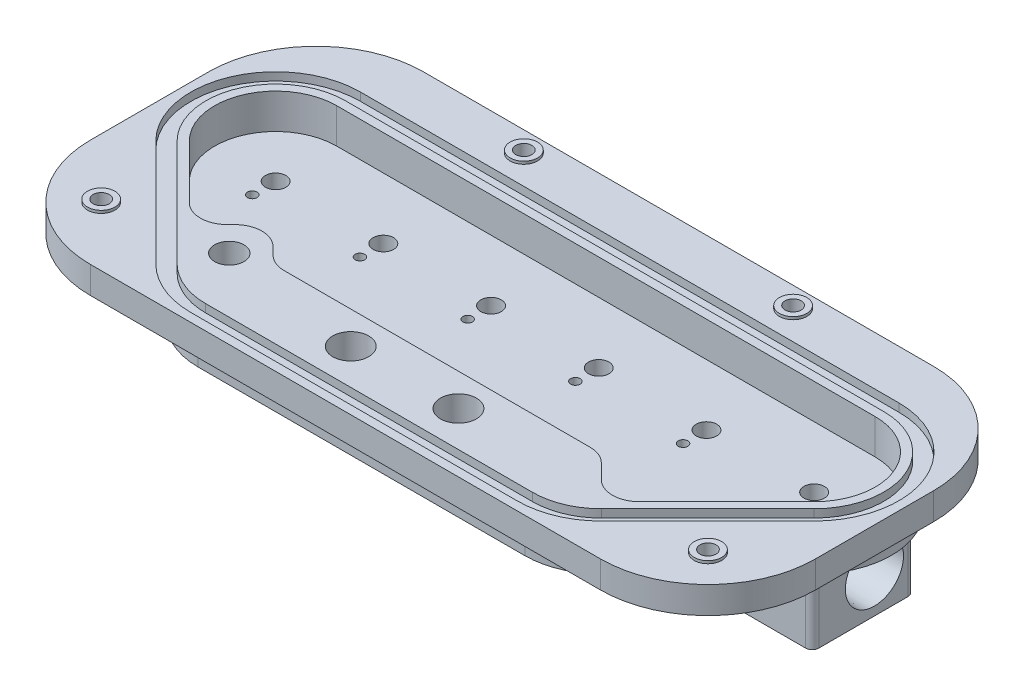
from build123d import *

# Parameters (mm, degrees)
BOSS_EXTRUDE1_DEPTH              = 12.065
SHELL1_T                         = -3.81
SKETCH3_W                        = 24.13
SKETCH3_H                        = 17.78
BOSS_EXTRUDE2_DEPTH              = 74.295
FILLET1_R                        = 1.5875
F_10_32_TAPPED_HOLE1_D           = 4.0386
F_10_32_TAPPED_HOLE1_DEPTH       = 12.02944
F_10_32_TAPPED_HOLE1_CBORE_D     = 4.826
F_10_32_TAPPED_HOLE1_CBORE_DEPTH = 9.652
F_10_32_TAPPED_HOLE1_TIP         = 1.213317848
F_7_16_0_4375_DIAMETER_HOLE5_D   = 11.1125
F_43_0_089_DIAMETER_HOLE2_D      = 2.2606
F_43_0_089_DIAMETER_HOLE2_DEPTH  = 36.068
F_43_0_089_DIAMETER_HOLE2_TIP    = 0.679152758
F_10_32_TAPPED_HOLE2_D           = 4.0386
F_10_32_TAPPED_HOLE2_DEPTH       = 5.08
F_10_32_TAPPED_HOLE2_CBORE_D     = 4.826
F_10_32_TAPPED_HOLE2_CBORE_DEPTH = 3.81
F_10_32_TAPPED_HOLE2_TIP         = 1.213317848
SKETCH12_W                       = 171.0436
SKETCH12_H                       = 78.613
BOSS_EXTRUDE3_DEPTH              = 6.35
BOSS_EXTRUDE6_DEPTH              = 8.255
FILLET5_R                        = 6.35
BOSS_EXTRUDE7_DEPTH              = 6.35
FILLET6_R                        = 6.35
F_4_40_TAPPED_HOLE1_D            = 2.2606
F_4_40_TAPPED_HOLE1_DEPTH        = 5.715
F_4_40_TAPPED_HOLE1_CBORE_D      = 2.8448
F_4_40_TAPPED_HOLE1_CBORE_DEPTH  = 3.81
F_4_40_TAPPED_HOLE1_TIP          = 0.679152758
F_5_16_24_TAPPED_HOLE1_D         = 6.9088
CUT_EXTRUDE7_DEPTH               = 1.905
FILLET7_R                        = 25.4
M10X1_5_TAPPED_HOLE1_D           = 8.5
F_6_CLEARANCE_HOLE1_D            = 3.7973
SKETCH59_R                       = 3.2385
SKETCH59_R_2                     = 1.89865
BOSS_EXTRUDE8_DEPTH              = 0.635
SKETCH64_R                       = 5.08
CUT_EXTRUDE9_DEPTH               = 5


with BuildPart() as part:
    # Sketch1 → Boss-Extrude1 (new body)
    with BuildSketch(Plane(origin=(0, 0, 0), x_dir=(1, 0, 0), z_dir=(0, 1, 0))):
        with BuildLine():
            Line((-63.5, 18.034), (63.5, 18.034))
            ThreePointArc((63.5, 18.034), (80.32550927, 6.791554134), (76.377687278, -13.055487278))
            Line((76.377687278, -13.055487278), (51.281210863, -38.151963692))
            ThreePointArc((51.281210863, -38.151963692), (45.430560191, -42.061243489), (38.529247171, -43.434))
            Line((38.529247171, -43.434), (-38.529247171, -43.434))
            ThreePointArc((-38.529247171, -43.434), (-45.430560191, -42.061243489), (-51.281210863, -38.151963692))
            Line((-51.281210863, -38.151963692), (-76.377687278, -13.055487278))
            ThreePointArc((-76.377687278, -13.055487278), (-80.32550927, 6.791554134), (-63.5, 18.034))
        make_face()
    extrude(amount=BOSS_EXTRUDE1_DEPTH)

    # Shell1
    shell1_openings = [part.faces().sort_by_distance(p)[0] for p in [
        (0, 12.065, 10.309491843),
    ]]
    offset(amount=SHELL1_T, openings=shell1_openings, kind=Kind.INTERSECTION)

    # Sketch3 → Boss-Extrude2 (add, symmetric)
    with BuildSketch(Plane(origin=(0, 0, 0), x_dir=(0, 0, -1), z_dir=(1, 0, 0))):
        with Locations((0.635, -8.89)):
            Rectangle(SKETCH3_W, SKETCH3_H)
    extrude(amount=BOSS_EXTRUDE2_DEPTH, both=True)

    # Fillet1
    fillet1_edges = [part.edges().sort_by_distance(p)[0] for p in [
        (-74.295, -8.89, 11.43),
        (-74.295, -8.89, -12.7),
        (74.295, -8.89, 11.43),
        (74.295, -8.89, -12.7),
    ]]
    fillet(fillet1_edges, radius=FILLET1_R)

    # #10-32 Tapped Hole1
    with Locations(Plane(origin=(0, 3.81, 0), x_dir=(1, 0, 0), z_dir=(0, 1, 0))):
        with Locations((-63.5, -0.1778), (-38.1, -0.1778), (-12.7, -0.1778), (12.7, -0.1778), (38.1, -0.1778), (63.5, -0.1778)):
            CounterBoreHole(F_10_32_TAPPED_HOLE1_D / 2, F_10_32_TAPPED_HOLE1_CBORE_D / 2, F_10_32_TAPPED_HOLE1_CBORE_DEPTH, depth=F_10_32_TAPPED_HOLE1_DEPTH)
            with Locations((0, 0, -(F_10_32_TAPPED_HOLE1_DEPTH + F_10_32_TAPPED_HOLE1_TIP / 2))):  # 118° drill point
                Cone(0, F_10_32_TAPPED_HOLE1_D / 2, F_10_32_TAPPED_HOLE1_TIP, mode=Mode.SUBTRACT)

    # 7/16 (0.4375) Diameter Hole5 (through all)
    with Locations(Plane.ZY.offset(74.295)):
        with Locations((-3.2385, -8.89)):
            Hole(F_7_16_0_4375_DIAMETER_HOLE5_D / 2)

    # Sketch61 → 1/4 NPT Tapped Hole2 (revolve, cut)
    with BuildSketch(Plane(origin=(74.295, -8.89, -3.2385), x_dir=(0, 0, -1), z_dir=(0, 1, 0))):
        Polygon((0, 0), (0, 156.0068), (5.5626, 156.0068), (5.5626, 9.906), (6.557984794, 9.906), (6.8545837, 0), align=None)
    revolve(axis=Axis((80.645, -8.89, -3.2385), (-1, 0, 0)), mode=Mode.SUBTRACT)

    # Sketch63 → 1/4 NPT Tapped Hole3 (revolve, cut)
    with BuildSketch(Plane(origin=(-74.295, -8.89, -3.2385), x_dir=(0, 0, 1), z_dir=(0, 1, 0))):
        Polygon((0, 0), (0, 156.0068), (5.5626, 156.0068), (5.5626, 9.906), (6.557984794, 9.906), (6.8545837, 0), align=None)
    revolve(axis=Axis((-80.645, -8.89, -3.2385), (1, 0, 0)), mode=Mode.SUBTRACT)

    # #43 (0.089) Diameter Hole2
    with Locations(Plane(origin=(0, 3.81, 0), x_dir=(1, 0, 0), z_dir=(0, 1, 0))):
        with Locations((-63.5, -5.6896), (-38.1, -5.6896), (-12.7, -5.6896), (12.7, -5.6896), (38.1, -5.6896), (63.5, -5.6896)):
            Hole(F_43_0_089_DIAMETER_HOLE2_D / 2, depth=F_43_0_089_DIAMETER_HOLE2_DEPTH)
            with Locations((0, 0, -(F_43_0_089_DIAMETER_HOLE2_DEPTH + F_43_0_089_DIAMETER_HOLE2_TIP / 2))):  # 118° drill point
                Cone(0, F_43_0_089_DIAMETER_HOLE2_D / 2, F_43_0_089_DIAMETER_HOLE2_TIP, mode=Mode.SUBTRACT)

    # #10-32 Tapped Hole2
    with Locations(Plane(origin=(0, -17.78, 0), x_dir=(-1, 0, 0), z_dir=(0, -1, 0))):
        with Locations((63.5, -5.6896), (38.1, -5.6896), (12.7, -5.6896), (-12.7, -5.6896), (-38.1, -5.6896), (-63.5, -5.6896)):
            CounterBoreHole(F_10_32_TAPPED_HOLE2_D / 2, F_10_32_TAPPED_HOLE2_CBORE_D / 2, F_10_32_TAPPED_HOLE2_CBORE_DEPTH, depth=F_10_32_TAPPED_HOLE2_DEPTH)
            with Locations((0, 0, -(F_10_32_TAPPED_HOLE2_DEPTH + F_10_32_TAPPED_HOLE2_TIP / 2))):  # 118° drill point
                Cone(0, F_10_32_TAPPED_HOLE2_D / 2, F_10_32_TAPPED_HOLE2_TIP, mode=Mode.SUBTRACT)

    # Sketch12 → Boss-Extrude3 (add)
    with BuildSketch(Plane(origin=(0, 12.065, 0), x_dir=(1, 0, 0), z_dir=(0, 1, 0))):
        with Locations((0, -7.9375)):
            Rectangle(SKETCH12_W, SKETCH12_H)
        with BuildLine():
            Line((63.5, 14.224), (-63.5, 14.224))
            ThreePointArc((-63.5, 14.224), (-76.805528251, 5.333530256), (-73.683610441, -10.361410441))
            Line((-73.683610441, -10.361410441), (-48.587134027, -35.457886856))
            ThreePointArc((-48.587134027, -35.457886856), (-43.972536313, -38.54126247), (-38.529247171, -39.624))
            Line((-38.529247171, -39.624), (38.529247171, -39.624))
            ThreePointArc((38.529247171, -39.624), (43.972536313, -38.54126247), (48.587134027, -35.457886856))
            Line((48.587134027, -35.457886856), (73.683610441, -10.361410441))
            ThreePointArc((73.683610441, -10.361410441), (76.805528251, 5.333530256), (63.5, 14.224))
        make_face(mode=Mode.SUBTRACT)
    extrude(amount=-BOSS_EXTRUDE3_DEPTH)

    # Sketch21 → Boss-Extrude6 (add)
    with BuildSketch(Plane(origin=(0, 3.81, 0), x_dir=(1, 0, 0), z_dir=(0, 1, 0))):
        with BuildLine():
            Line((-56.594969658, -27.450051224), (-48.587134027, -35.457886856))
            ThreePointArc((-48.587134027, -35.457886856), (-43.972536313, -38.54126247), (-38.529247171, -39.624))
            Line((-38.529247171, -39.624), (38.529247171, -39.624))
            ThreePointArc((38.529247171, -39.624), (43.972536313, -38.54126247), (48.587134027, -35.457886856))
            Line((48.587134027, -35.457886856), (38.783247171, -25.654))
            Line((38.783247171, -25.654), (-38.634457416, -25.654))
            Line((-38.634457416, -25.654), (-46.716687925, -17.571769491))
            Line((-46.716687925, -17.571769491), (-56.594969658, -27.450051224))
        make_face()
    extrude(amount=BOSS_EXTRUDE6_DEPTH)

    # Fillet5
    fillet5_edges = [part.edges().sort_by_distance(p)[0] for p in [
        (48.587134027, 7.9375, 35.457886856),
        (38.783247171, 7.9375, 25.654),
        (-38.634457416, 7.9375, 25.654),
        (-46.716687925, 7.9375, 17.571769491),
        (-56.594969658, 7.9375, 27.450051224),
    ]]
    fillet(fillet5_edges, radius=FILLET5_R)

    # Sketch28 → Boss-Extrude7 (add)
    with BuildSketch(Plane.XZ):
        with BuildLine():
            Line((-25.248364969, 23.131039796), (-20.401635591, 11.43))
            Line((-20.401635591, 11.43), (-41.828364409, 11.43))
            Line((-41.828364409, 11.43), (-36.981635031, 23.131039796))
            ThreePointArc((-36.981635031, 23.131039796), (-31.115, 27.051), (-25.248364969, 23.131039796))
        make_face()
        with BuildLine():
            Line((25.248364969, 23.131039796), (20.401635591, 11.43))
            Line((20.401635591, 11.43), (41.828364409, 11.43))
            Line((41.828364409, 11.43), (36.981635031, 23.131039796))
            ThreePointArc((36.981635031, 23.131039796), (31.115, 27.051), (25.248364969, 23.131039796))
        make_face()
    extrude(amount=BOSS_EXTRUDE7_DEPTH)

    # Fillet6
    fillet6_edges = [part.edges().sort_by_distance(p)[0] for p in [
        (-41.828364409, -3.175, 11.43),
        (-20.401635591, -3.175, 11.43),
        (20.401635591, -3.175, 11.43),
        (41.828364409, -3.175, 11.43),
    ]]
    fillet(fillet6_edges, radius=FILLET6_R)

    # #4-40 Tapped Hole1
    with Locations(Plane(origin=(0, 3.81, 0), x_dir=(1, 0, 0), z_dir=(0, 1, 0))):
        with Locations((-31.115, -20.701), (31.115, -20.701)):
            CounterBoreHole(F_4_40_TAPPED_HOLE1_D / 2, F_4_40_TAPPED_HOLE1_CBORE_D / 2, F_4_40_TAPPED_HOLE1_CBORE_DEPTH, depth=F_4_40_TAPPED_HOLE1_DEPTH)
            with Locations((0, 0, -(F_4_40_TAPPED_HOLE1_DEPTH + F_4_40_TAPPED_HOLE1_TIP / 2))):  # 118° drill point
                Cone(0, F_4_40_TAPPED_HOLE1_D / 2, F_4_40_TAPPED_HOLE1_TIP, mode=Mode.SUBTRACT)

    # 5/16-24 Tapped Hole1 (through all)
    with Locations(Plane(origin=(0, 0, 0), x_dir=(-1, 0, 0), z_dir=(0, -1, 0))):
        with Locations((46.0375, -28.575)):
            Hole(F_5_16_24_TAPPED_HOLE1_D / 2)

    # Sketch54 → Cut-Extrude7 (cut)
    with BuildSketch(Plane(origin=(0, 12.065, -12.065), x_dir=(1, 0, 0), z_dir=(0, -1, 0))):
        with BuildLine():
            Line((38.529247171, 57.277), (-38.529247171, 57.277))
            ThreePointArc((-38.529247171, 57.277), (-46.110971333, 55.768901298), (-52.53844672, 51.474199549))
            Line((-52.53844672, 51.474199549), (-77.634923135, 26.377723135))
            ThreePointArc((-77.634923135, 26.377723135), (-81.968167079, 4.593034724), (-63.5, -7.747))
            Line((-63.5, -7.747), (63.5, -7.747))
            ThreePointArc((63.5, -7.747), (81.968167079, 4.593034724), (77.634923135, 26.377723135))
            Line((77.634923135, 26.377723135), (52.53844672, 51.474199549))
            ThreePointArc((52.53844672, 51.474199549), (46.110971333, 55.768901298), (38.529247171, 57.277))
        make_face()
        with BuildLine():
            Line((50.023975006, 48.959727835), (75.120451421, 23.863251421))
            ThreePointArc((75.120451421, 23.863251421), (78.682851461, 5.953857009), (63.5, -4.191))
            Line((63.5, -4.191), (-63.5, -4.191))
            ThreePointArc((-63.5, -4.191), (-78.682851461, 5.953857009), (-75.120451421, 23.863251421))
            Line((-75.120451421, 23.863251421), (-50.023975006, 48.959727835))
            ThreePointArc((-50.023975006, 48.959727835), (-44.750149048, 52.483585681), (-38.529247171, 53.721))
            Line((-38.529247171, 53.721), (38.529247171, 53.721))
            ThreePointArc((38.529247171, 53.721), (44.750149048, 52.483585681), (50.023975006, 48.959727835))
        make_face(mode=Mode.SUBTRACT)
    extrude(amount=CUT_EXTRUDE7_DEPTH, mode=Mode.SUBTRACT)

    # Fillet7
    fillet7_edges = [part.edges().sort_by_distance(p)[0] for p in [
        (-85.5218, 8.89, -31.369),
        (85.5218, 8.89, -31.369),
        (85.5218, 8.89, 47.244),
        (-85.5218, 8.89, 47.244),
    ]]
    fillet(fillet7_edges, radius=FILLET7_R)

    # M10x1.5 Tapped Hole1 (through all)
    with Locations(Plane(origin=(0, 12.065, 0), x_dir=(1, 0, 0), z_dir=(0, 1, 0))):
        with Locations((-12.7, -33.274), (12.7, -33.274)):
            Hole(M10X1_5_TAPPED_HOLE1_D / 2)

    # #6 Clearance Hole1 (through all)
    with Locations(Plane(origin=(0, 12.065, 0), x_dir=(1, 0, 0), z_dir=(0, 1, 0))):
        with Locations((-71.5518, -33.274), (-31.75, 26.6065), (71.5518, -33.274), (31.75, 26.6065)):
            Hole(F_6_CLEARANCE_HOLE1_D / 2)

    # Sketch59 → Boss-Extrude8 (add)
    with BuildSketch(Plane(origin=(0, 12.065, 0), x_dir=(1, 0, 0), z_dir=(0, 1, 0))):
        with Locations(Location((-31.75, 26.6065, 0), (0, 0, 270))):
            Circle(SKETCH59_R)
        with Locations(Location((-31.75, 26.6065, 0), (0, 0, 270))):
            Circle(SKETCH59_R_2, mode=Mode.SUBTRACT)
        with Locations(Location((-71.5518, -33.274, 0), (0, 0, 270))):
            Circle(SKETCH59_R)
        with Locations(Location((-71.5518, -33.274, 0), (0, 0, 270))):
            Circle(SKETCH59_R_2, mode=Mode.SUBTRACT)
        with Locations(Location((71.5518, -33.274, 0), (0, 0, 90))):
            Circle(SKETCH59_R)
        with Locations(Location((71.5518, -33.274, 0), (0, 0, 270))):
            Circle(SKETCH59_R_2, mode=Mode.SUBTRACT)
        with Locations(Location((31.75, 26.6065, 0), (0, 0, 90))):
            Circle(SKETCH59_R)
        with Locations(Location((31.75, 26.6065, 0), (0, 0, 270))):
            Circle(SKETCH59_R_2, mode=Mode.SUBTRACT)
    extrude(amount=BOSS_EXTRUDE8_DEPTH)

    # Sketch64 → Cut-Extrude9 (cut)
    with BuildSketch(Plane.XZ):
        with Locations(Location((-12.7, 33.274, 0), (0, 0, 270))):
            Circle(SKETCH64_R)
        with Locations(Location((12.7, 33.274, 0), (0, 0, 270))):
            Circle(SKETCH64_R)
    extrude(amount=-CUT_EXTRUDE9_DEPTH, mode=Mode.SUBTRACT)


solid = part.part
